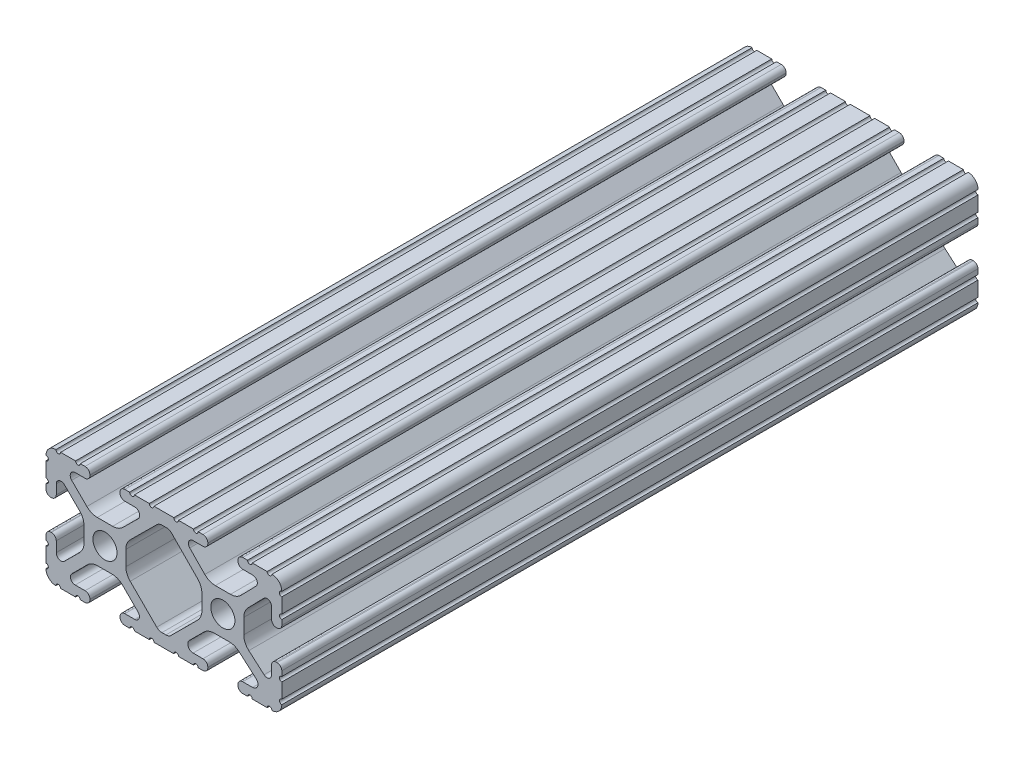
from build123d import *

# Parameters (mm, degrees)
SKETCH1_R      = 2.6035
EXTRUDE1_DEPTH = 150


with BuildPart() as part:
    # Sketch1 → Extrude1 (new body)
    with BuildSketch(Plane.XY):
        with BuildLine():
            Line((9.5504, 12.7), (6.33310265, 12.7))
            ThreePointArc((6.33310265, 12.7), (5.82510265, 12.192), (5.31710265, 12.7))
            Line((5.31710265, 12.7), (4.28745015, 12.7))
            ThreePointArc((4.28745015, 12.7), (3.545730386, 12.392769614), (3.2385, 11.65104985))
            Line((3.2385, 11.65104985), (3.2385, 11.53922))
            ThreePointArc((3.2385, 11.53922), (3.545750844, 10.797450844), (4.28752, 10.4902))
            Line((4.28752, 10.4902), (6.416384363, 10.4902))
            ThreePointArc((6.416384363, 10.4902), (7.352502933, 9.869096983), (7.144087081, 8.765172272))
            Line((7.144087081, 8.765172272), (3.918993479, 5.455112286))
            ThreePointArc((3.918993479, 5.455112286), (2.878994274, 4.745442459), (1.644932584, 4.4958))
            Line((1.644932584, 4.4958), (-1.616682165, 4.4958))
            ThreePointArc((-1.616682165, 4.4958), (-2.845669047, 4.743306833), (-3.883044811, 5.447238587))
            Line((-3.883044811, 5.447238587), (-7.135845881, 8.762652677))
            ThreePointArc((-7.135845881, 8.762652677), (-7.347408588, 9.867473037), (-6.410606615, 10.4902))
            Line((-6.410606615, 10.4902), (-4.28752, 10.4902))
            ThreePointArc((-4.28752, 10.4902), (-3.545750844, 10.797450844), (-3.2385, 11.53922))
            Line((-3.2385, 11.53922), (-3.2385, 11.65104985))
            ThreePointArc((-3.2385, 11.65104985), (-3.545730386, 12.392769614), (-4.28745015, 12.7))
            Line((-4.28745015, 12.7), (-5.31711535, 12.7))
            ThreePointArc((-5.31711535, 12.7), (-5.82511535, 12.192), (-6.33311535, 12.7))
            Line((-6.33311535, 12.7), (-9.55041905, 12.7))
            ThreePointArc((-9.55041905, 12.7), (-10.05841905, 12.192), (-10.56641905, 12.7))
            Line((-10.56641905, 12.7), (-14.83358095, 12.7))
            ThreePointArc((-14.83358095, 12.7), (-15.34158095, 12.192), (-15.84958095, 12.7))
            Line((-15.84958095, 12.7), (-19.06689735, 12.7))
            ThreePointArc((-19.06689735, 12.7), (-19.57489735, 12.192), (-20.08289735, 12.7))
            Line((-20.08289735, 12.7), (-21.11254985, 12.7))
            ThreePointArc((-21.11254985, 12.7), (-21.854269614, 12.392769614), (-22.1615, 11.65104985))
            Line((-22.1615, 11.65104985), (-22.1615, 11.53922))
            ThreePointArc((-22.1615, 11.53922), (-21.854249156, 10.797450844), (-21.11248, 10.4902))
            Line((-21.11248, 10.4902), (-18.983641037, 10.4902))
            ThreePointArc((-18.983641037, 10.4902), (-17.997291557, 9.829633109), (-18.232576693, 8.666071843))
            Line((-18.232576693, 8.666071843), (-21.509985098, 5.416263103))
            ThreePointArc((-21.509985098, 5.416263103), (-22.536720513, 4.734920264), (-23.745536121, 4.4958))
            Line((-23.745536121, 4.4958), (-27.054463879, 4.4958))
            ThreePointArc((-27.054463879, 4.4958), (-28.263279487, 4.734920264), (-29.290014902, 5.416263103))
            Line((-29.290014902, 5.416263103), (-32.567423307, 8.666071843))
            ThreePointArc((-32.567423307, 8.666071843), (-32.802708443, 9.829633109), (-31.816358963, 10.4902))
            Line((-31.816358963, 10.4902), (-29.68752, 10.4902))
            ThreePointArc((-29.68752, 10.4902), (-28.945750844, 10.797450844), (-28.6385, 11.53922))
            Line((-28.6385, 11.53922), (-28.6385, 11.65104985))
            ThreePointArc((-28.6385, 11.65104985), (-28.945730386, 12.392769614), (-29.68745015, 12.7))
            Line((-29.68745015, 12.7), (-30.71711535, 12.7))
            ThreePointArc((-30.71711535, 12.7), (-31.22511535, 12.192), (-31.73311535, 12.7))
            Line((-31.73311535, 12.7), (-34.9504, 12.7))
            ThreePointArc((-34.9504, 12.7), (-35.458323491, 12.192000006), (-35.966399977, 12.699846982))
            ThreePointArc((-35.966399977, 12.699846982), (-37.482522516, 12.082522516), (-38.099846982, 10.566399977))
            ThreePointArc((-38.099846982, 10.566399977), (-37.592000006, 10.058323491), (-38.1, 9.5504))
            Line((-38.1, 9.5504), (-38.1, 6.3330836))
            ThreePointArc((-38.1, 6.3330836), (-37.592, 5.8250836), (-38.1, 5.3170836))
            Line((-38.1, 5.3170836), (-38.1, 4.237520184))
            ThreePointArc((-38.1, 4.237520184), (-37.807393763, 3.531106237), (-37.100979816, 3.2385))
            Line((-37.100979816, 3.2385), (-36.93922, 3.2385))
            ThreePointArc((-36.93922, 3.2385), (-36.197450844, 3.545750844), (-35.8902, 4.28752))
            Line((-35.8902, 4.28752), (-35.8902, 6.334741132))
            ThreePointArc((-35.8902, 6.334741132), (-35.256026952, 7.286023527), (-34.134002553, 7.066535717))
            Line((-34.134002553, 7.066535717), (-30.847950853, 3.808156468))
            ThreePointArc((-30.847950853, 3.808156468), (-30.152759693, 2.774838327), (-29.908501877, 1.553619571))
            Line((-29.908501877, 1.553619571), (-29.908501877, -1.695179196))
            ThreePointArc((-29.908501877, -1.695179196), (-30.150738657, -2.911536421), (-30.840486065, -3.942289578))
            Line((-30.840486065, -3.942289578), (-34.131579576, -7.227386226))
            ThreePointArc((-34.131579576, -7.227386226), (-35.25444896, -7.449940594), (-35.8902, -6.498002195))
            Line((-35.8902, -6.498002195), (-35.8902, -4.28752))
            ThreePointArc((-35.8902, -4.28752), (-36.197450844, -3.545750844), (-36.93922, -3.2385))
            Line((-36.93922, -3.2385), (-37.05098, -3.2385))
            ThreePointArc((-37.05098, -3.2385), (-37.792749156, -3.545750844), (-38.1, -4.28752))
            Line((-38.1, -4.28752), (-38.1, -5.3171344))
            ThreePointArc((-38.1, -5.3171344), (-37.592, -5.8251344), (-38.1, -6.3331344))
            Line((-38.1, -6.3331344), (-38.1, -9.5504))
            ThreePointArc((-38.1, -9.5504), (-37.592000006, -10.058323491), (-38.099846982, -10.566399977))
            ThreePointArc((-38.099846982, -10.566399977), (-37.482522516, -12.082522516), (-35.966399977, -12.699846982))
            ThreePointArc((-35.966399977, -12.699846982), (-35.458323491, -12.192000006), (-34.9504, -12.7))
            Line((-34.9504, -12.7), (-31.73308995, -12.7))
            ThreePointArc((-31.73308995, -12.7), (-31.22508995, -12.192), (-30.71708995, -12.7))
            Line((-30.71708995, -12.7), (-29.6874692, -12.7))
            ThreePointArc((-29.6874692, -12.7), (-28.945700044, -12.392749156), (-28.6384492, -11.65098))
            Line((-28.6384492, -11.65098), (-28.6384492, -11.53922))
            ThreePointArc((-28.6384492, -11.53922), (-28.945700044, -10.797450844), (-29.6874692, -10.4902))
            Line((-29.6874692, -10.4902), (-31.816358963, -10.4902))
            ThreePointArc((-31.816358963, -10.4902), (-32.755197748, -9.862578342), (-32.534124023, -8.755124678))
            Line((-32.534124023, -8.755124678), (-29.19660751, -5.423689618))
            ThreePointArc((-29.19660751, -5.423689618), (-28.167274017, -4.736928798), (-26.953591699, -4.4958))
            Line((-26.953591699, -4.4958), (-23.846408301, -4.4958))
            ThreePointArc((-23.846408301, -4.4958), (-22.632725983, -4.736928798), (-21.60339249, -5.423689618))
            Line((-21.60339249, -5.423689618), (-18.265875977, -8.755124678))
            ThreePointArc((-18.265875977, -8.755124678), (-18.044802252, -9.862578342), (-18.983641037, -10.4902))
            Line((-18.983641037, -10.4902), (-21.1125308, -10.4902))
            ThreePointArc((-21.1125308, -10.4902), (-21.854299956, -10.797450844), (-22.1615508, -11.53922))
            Line((-22.1615508, -11.53922), (-22.1615508, -11.65098))
            ThreePointArc((-22.1615508, -11.65098), (-21.854299956, -12.392749156), (-21.1125308, -12.7))
            Line((-21.1125308, -12.7), (-20.08287195, -12.7))
            ThreePointArc((-20.08287195, -12.7), (-19.57487195, -12.192), (-19.06687195, -12.7))
            Line((-19.06687195, -12.7), (-15.84960635, -12.7))
            ThreePointArc((-15.84960635, -12.7), (-15.34160635, -12.192), (-14.83360635, -12.7))
            Line((-14.83360635, -12.7), (-10.56639365, -12.7))
            ThreePointArc((-10.56639365, -12.7), (-10.05840635, -12.1920127), (-9.55041905, -12.7))
            Line((-9.55041905, -12.7), (-6.33308995, -12.7))
            ThreePointArc((-6.33308995, -12.7), (-5.82508995, -12.192), (-5.31708995, -12.7))
            Line((-5.31708995, -12.7), (-4.2874692, -12.7))
            ThreePointArc((-4.2874692, -12.7), (-3.545700044, -12.392749156), (-3.2384492, -11.65098))
            Line((-3.2384492, -11.65098), (-3.2384492, -11.53922))
            ThreePointArc((-3.2384492, -11.53922), (-3.545700044, -10.797450844), (-4.2874692, -10.4902))
            Line((-4.2874692, -10.4902), (-6.410606615, -10.4902))
            ThreePointArc((-6.410606615, -10.4902), (-7.468409678, -9.783049717), (-7.219322755, -8.535265862))
            Line((-7.219322755, -8.535265862), (-4.102066405, -5.423689618))
            ThreePointArc((-4.102066405, -5.423689618), (-3.072732912, -4.736928798), (-1.859050594, -4.4958))
            Line((-1.859050594, -4.4958), (1.402564155, -4.4958))
            ThreePointArc((1.402564155, -4.4958), (2.515927525, -4.697410182), (3.487895372, -5.276636531))
            Line((3.487895372, -5.276636531), (7.168247549, -8.482246082))
            ThreePointArc((7.168247549, -8.482246082), (7.488435806, -9.746879864), (6.416384363, -10.4902))
            Line((6.416384363, -10.4902), (4.2874692, -10.4902))
            ThreePointArc((4.2874692, -10.4902), (3.545700044, -10.797450844), (3.2384492, -11.53922))
            Line((3.2384492, -11.53922), (3.2384492, -11.65098))
            ThreePointArc((3.2384492, -11.65098), (3.545700044, -12.392749156), (4.2874692, -12.7))
            Line((4.2874692, -12.7), (5.31710265, -12.7))
            ThreePointArc((5.31710265, -12.7), (5.82510265, -12.192), (6.33310265, -12.7))
            Line((6.33310265, -12.7), (9.5504, -12.7))
            ThreePointArc((9.5504, -12.7), (10.058323491, -12.192000006), (10.566399977, -12.699846982))
            ThreePointArc((10.566399977, -12.699846982), (12.082522516, -12.082522516), (12.699846982, -10.566399977))
            ThreePointArc((12.699846982, -10.566399977), (12.192000006, -10.058323492), (12.7, -9.550400001))
            Line((12.7, -9.550400001), (12.7, -6.333083592))
            ThreePointArc((12.7, -6.333083592), (12.192000001, -5.825083593), (12.7, -5.317083593))
            Line((12.7, -5.317083593), (12.7, -4.237520184))
            ThreePointArc((12.7, -4.237520184), (12.407393763, -3.531106237), (11.700979816, -3.2385))
            Line((11.700979816, -3.2385), (11.489220184, -3.2385))
            ThreePointArc((11.489220184, -3.2385), (10.782806237, -3.531106237), (10.4902, -4.237520184))
            Line((10.4902, -4.237520184), (10.4902, -6.155876159))
            ThreePointArc((10.4902, -6.155876159), (9.92232736, -7.038258539), (8.883974541, -6.886926384))
            Line((8.883974541, -6.886926384), (5.59817066, -4.024970844))
            ThreePointArc((5.59817066, -4.024970844), (4.793730985, -2.946044689), (4.508501877, -1.630807374))
            Line((4.508501877, -1.630807374), (4.508501877, 1.630807374))
            ThreePointArc((4.508501877, 1.630807374), (4.742348332, 2.82673414), (5.409440981, 3.846495088))
            Line((5.409440981, 3.846495088), (8.826346532, 7.353420386))
            ThreePointArc((8.826346532, 7.353420386), (9.885896263, 7.574939077), (10.4902, 6.676867167))
            Line((10.4902, 6.676867167), (10.4902, 4.237520184))
            ThreePointArc((10.4902, 4.237520184), (10.782806237, 3.531106237), (11.489220184, 3.2385))
            Line((11.489220184, 3.2385), (11.700979816, 3.2385))
            ThreePointArc((11.700979816, 3.2385), (12.407393763, 3.531106237), (12.7, 4.237520184))
            Line((12.7, 4.237520184), (12.7, 5.3170836))
            ThreePointArc((12.7, 5.3170836), (12.191949193, 5.825134407), (12.7, 6.333185215))
            Line((12.7, 6.333185215), (12.7, 9.550400015))
            ThreePointArc((12.7, 9.550400015), (12.192000013, 10.058323498), (12.699846982, 10.566399977))
            ThreePointArc((12.699846982, 10.566399977), (12.082522516, 12.082522516), (10.566399977, 12.699846982))
            ThreePointArc((10.566399977, 12.699846982), (10.058323491, 12.192000006), (9.5504, 12.7))
        make_face()
        with Locations((-25.4, 0)):
            Circle(SKETCH1_R, mode=Mode.SUBTRACT)
        Circle(SKETCH1_R, mode=Mode.SUBTRACT)
        with BuildLine():
            Line((-19.959513935, -3.869413038), (-14.245748891, -9.572766749))
            ThreePointArc((-14.245748891, -9.572766749), (-13.735199478, -9.913400116), (-13.133213048, -10.033))
            Line((-13.133213048, -10.033), (-12.266786952, -10.033))
            ThreePointArc((-12.266786952, -10.033), (-11.664800522, -9.913400116), (-11.154251109, -9.572766749))
            Line((-11.154251109, -9.572766749), (-5.440486065, -3.869413038))
            ThreePointArc((-5.440486065, -3.869413038), (-4.750738657, -2.838659881), (-4.508501877, -1.622302656))
            Line((-4.508501877, -1.622302656), (-4.508501877, 1.622302656))
            ThreePointArc((-4.508501877, 1.622302656), (-4.744426648, 2.823327967), (-5.417139231, 3.845864069))
            Line((-5.417139231, 3.845864069), (-11.024427192, 9.561086461))
            ThreePointArc((-11.024427192, 9.561086461), (-11.538965571, 9.910236611), (-12.148543064, 10.033))
            Line((-12.148543064, 10.033), (-13.095199982, 10.033))
            ThreePointArc((-13.095199982, 10.033), (-13.694772524, 9.914396349), (-14.20403329, 9.576450301))
            Line((-14.20403329, 9.576450301), (-19.952049147, 3.876839553))
            ThreePointArc((-19.952049147, 3.876839553), (-20.647240307, 2.843521412), (-20.891498123, 1.622302656))
            Line((-20.891498123, 1.622302656), (-20.891498123, -1.622302656))
            ThreePointArc((-20.891498123, -1.622302656), (-20.649261343, -2.838659881), (-19.959513935, -3.869413038))
        make_face(mode=Mode.SUBTRACT)
    extrude(amount=-EXTRUDE1_DEPTH)


solid = part.part
